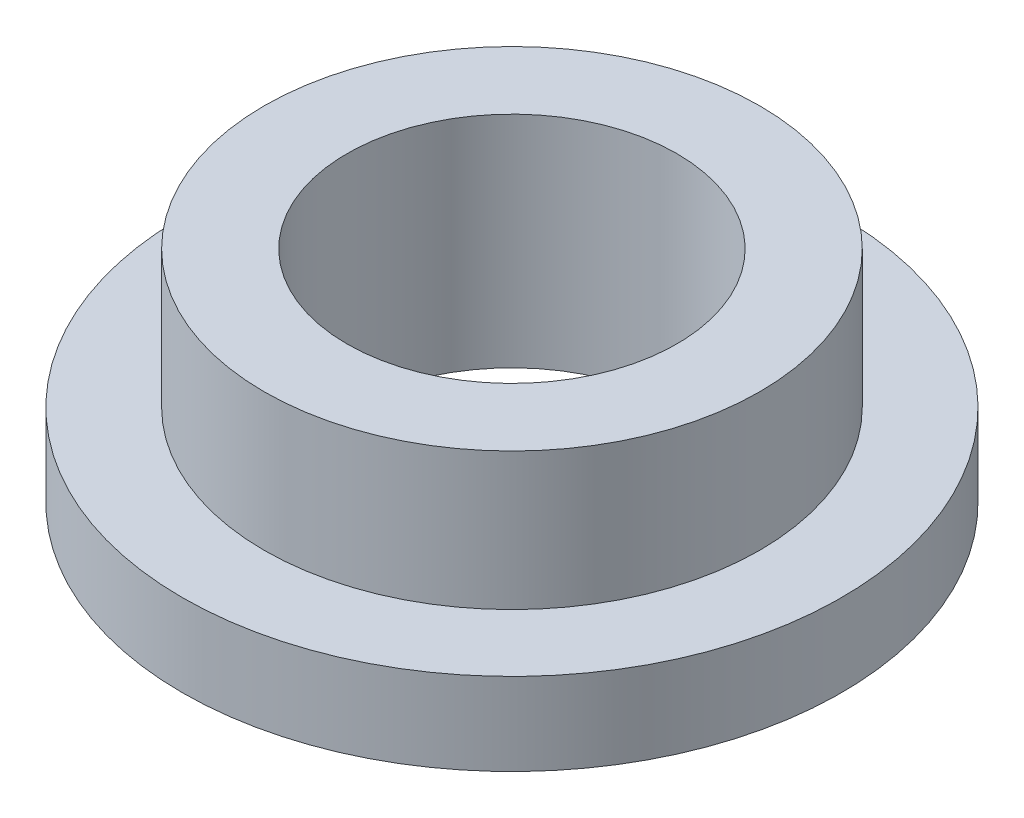
from build123d import *

# Parameters (mm, degrees)
SKETCH2_R           = 9.02
SKETCH2_R_2         = 6.005
BOSS_EXTRUDE1_DEPTH = 8
SKETCH3_R           = 12
SKETCH3_R_2         = 9.02
BOSS_EXTRUDE2_DEPTH = 3


with BuildPart() as part:
    # Sketch2 → Boss-Extrude1 (new body)
    with BuildSketch(Plane(origin=(0, 0, 0), x_dir=(1, 0, 0), z_dir=(0, 1, 0))):
        Circle(SKETCH2_R)
        Circle(SKETCH2_R_2, mode=Mode.SUBTRACT)
    extrude(amount=BOSS_EXTRUDE1_DEPTH)

    # Sketch3 → Boss-Extrude2 (add)
    with BuildSketch(Plane(origin=(0, 0, 0), x_dir=(1, 0, 0), z_dir=(0, 1, 0))):
        Circle(SKETCH3_R)
        Circle(SKETCH3_R_2, mode=Mode.SUBTRACT)
    extrude(amount=BOSS_EXTRUDE2_DEPTH)


solid = part.part
